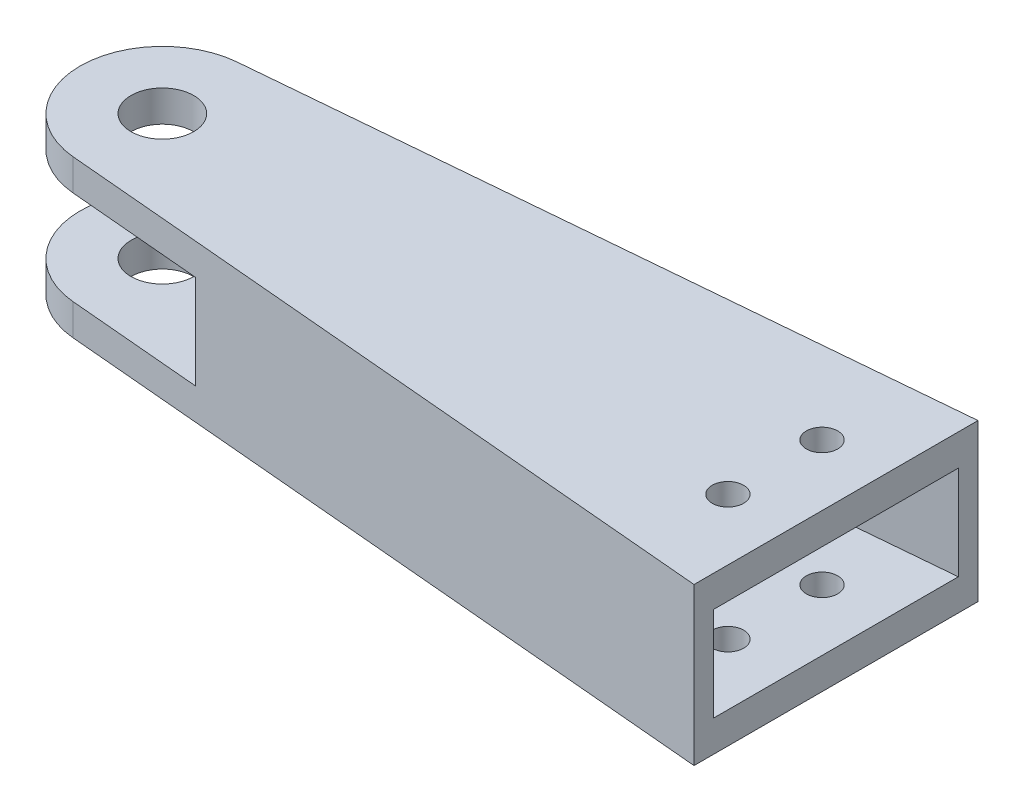
from build123d import *

# Parameters (mm, degrees)
SKETCH1_R           = 4
BOSS_EXTRUDE1_DEPTH = 4
SKETCH2_R           = 4
BOSS_EXTRUDE2_DEPTH = 4
BOSS_EXTRUDE5_DEPTH = 12
SKETCH6_R           = 2
CUT_EXTRUDE1_DEPTH  = 21
BOSS_EXTRUDE6_DEPTH = 12


with BuildPart() as part:
    # Sketch1 → Boss-Extrude1 (new body)
    with BuildSketch(Plane(origin=(0, 0, 0), x_dir=(1, 0, 0), z_dir=(0, 1, 0))):
        with BuildLine():
            Line((-75, 18.10605947), (-161.821193893, 10.459512504))
            ThreePointArc((-161.821193893, 10.459512504), (-171.4, 0), (-161.821193893, -10.459512504))
            Line((-161.821193893, -10.459512504), (-75, -18.10605947))
            Line((-75, -18.10605947), (-75, 18.10605947))
        make_face()
        with Locations((-160.9, 0)):
            Circle(SKETCH1_R, mode=Mode.SUBTRACT)
    extrude(amount=BOSS_EXTRUDE1_DEPTH)



with BuildPart() as body_2:
    # Sketch2 → Boss-Extrude2 (new body)
    with BuildSketch(Plane(origin=(0, 16, 0), x_dir=(1, 0, 0), z_dir=(0, 1, 0))):
        with BuildLine():
            Line((-75, 18.10605947), (-161.821193893, 10.459512504))
            ThreePointArc((-161.821193893, 10.459512504), (-171.4, 0), (-161.821193893, -10.459512504))
            Line((-161.821193893, -10.459512504), (-75, -18.10605947))
            Line((-75, -18.10605947), (-75, 18.10605947))
        make_face()
        with Locations((-160.9, 0)):
            Circle(SKETCH2_R, mode=Mode.SUBTRACT)
    extrude(amount=BOSS_EXTRUDE2_DEPTH)


with BuildPart() as part_1:
    add(part.part)

    add(body_2.part)  # Boss-Extrude5 merges body 2
    # Sketch5 → Boss-Extrude5 (add)
    with BuildSketch(Plane(origin=(0, 4, 0), x_dir=(1, 0, 0), z_dir=(0, 1, 0))):
        Polygon((-75, -18.10605947), (-75, -15.596382275), (-144.510751478, -9.47440673), (-144.730083357, -11.964766849), align=None)
        Polygon((-75, 15.596382275), (-75, 18.10605947), (-144.730083357, 11.964766849), (-144.510751478, 9.47440673), align=None)
    extrude(amount=BOSS_EXTRUDE5_DEPTH)

    # Sketch6 → Cut-Extrude1 (cut, through all)
    with BuildSketch(Plane(origin=(0, 0, 0), x_dir=(-1, 0, 0), z_dir=(0, -1, 0))):
        with Locations((82.8, -5.982385529)):
            Circle(SKETCH6_R)
        with Locations((82.8, 6.017614471)):
            Circle(SKETCH6_R)
    extrude(amount=-CUT_EXTRUDE1_DEPTH, mode=Mode.SUBTRACT)

    # Sketch7 → Boss-Extrude6 (add)
    with BuildSketch(Plane(origin=(0, 4, 0), x_dir=(1, 0, 0), z_dir=(0, 1, 0))):
        Polygon((-144.510751478, 9.47440673), (-144.510751478, -9.47440673), (-95, -13.834935185), (-95, 13.834935185), align=None)
    extrude(amount=BOSS_EXTRUDE6_DEPTH)


solid = part_1.part
